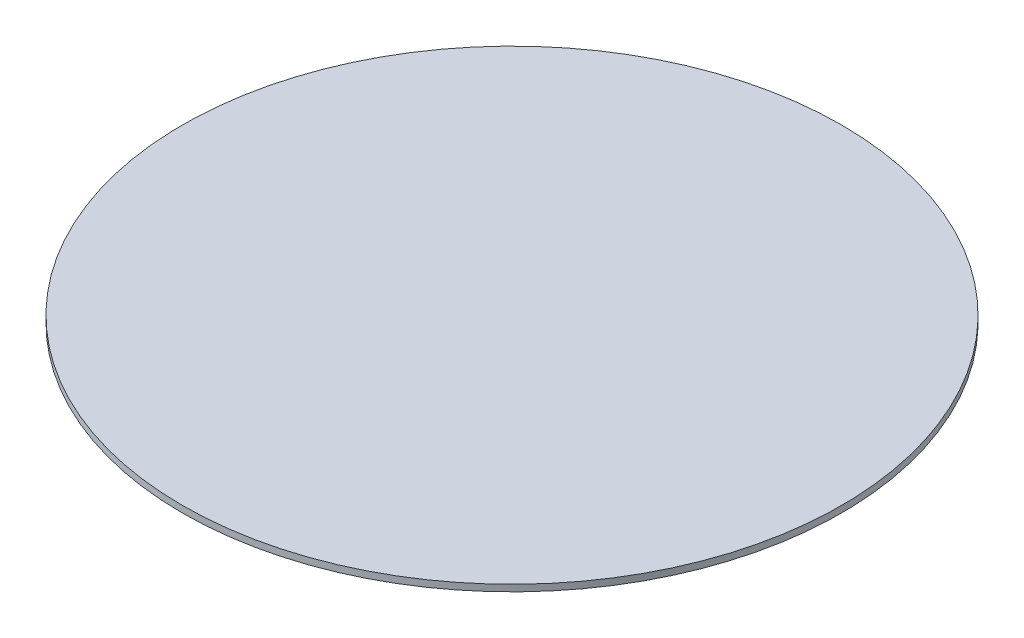
from build123d import *

# Parameters (mm, degrees)
SKETCH1_R           = 25
BOSS_EXTRUDE1_DEPTH = 0.5


with BuildPart() as part:
    # Sketch1 → Boss-Extrude1 (new body)
    with BuildSketch(Plane(origin=(0, 0, 0), x_dir=(1, 0, 0), z_dir=(0, 1, 0))):
        Circle(SKETCH1_R)
    extrude(amount=BOSS_EXTRUDE1_DEPTH)


solid = part.part
